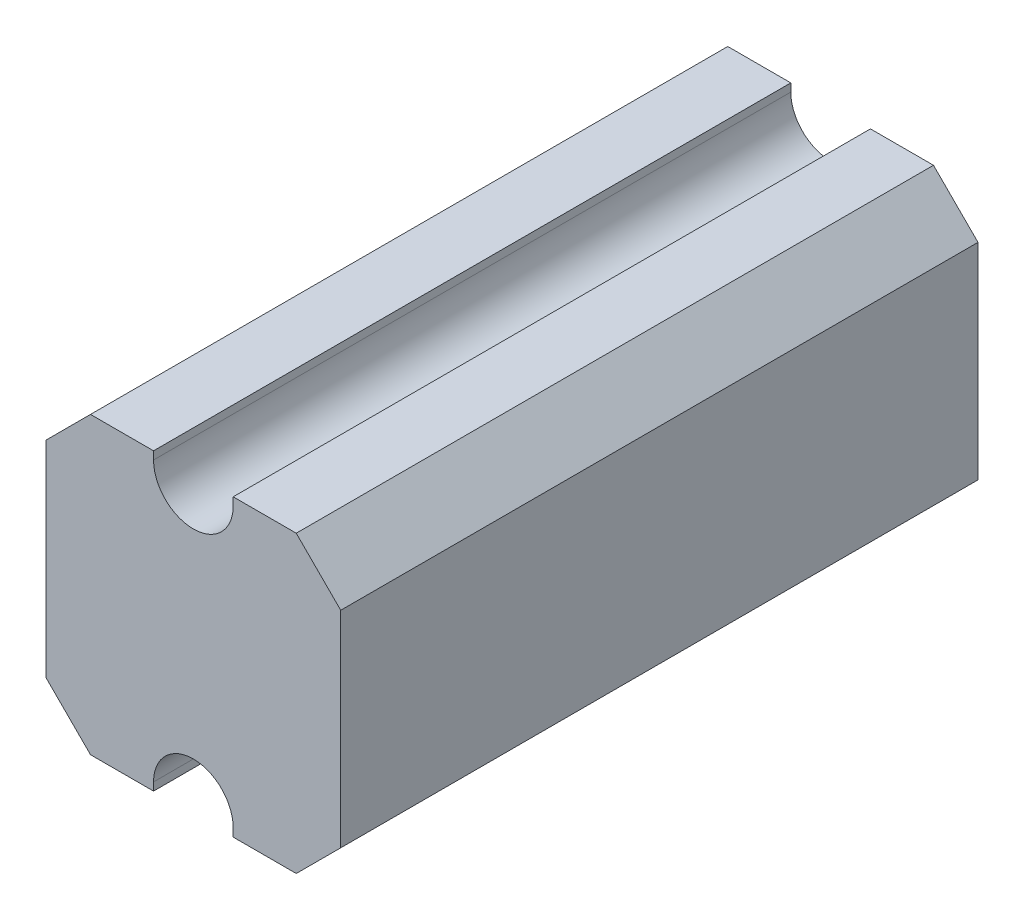
from build123d import *

# Parameters (mm, degrees)
BOSS_EXTRUDE1_DEPTH = 800


with BuildPart() as part:
    # Sketch1 → Boss-Extrude1 (new body)
    with BuildSketch(Plane.XY):
        with BuildLine():
            Line((-185, 129.142135624), (-185, -129.142135624))
            Line((-185, -129.142135624), (-129.142135624, -185))
            Line((-129.142135624, -185), (-50, -185))
            Line((-50, -185), (-50, -175))
            ThreePointArc((-50, -175), (0, -125), (50, -175))
            Line((50, -175), (50, -185))
            Line((50, -185), (129.142135624, -185))
            Line((129.142135624, -185), (185, -129.142135624))
            Line((185, -129.142135624), (185, 129.142135624))
            Line((185, 129.142135624), (129.142135624, 185))
            Line((129.142135624, 185), (50, 185))
            Line((50, 185), (50, 175))
            ThreePointArc((50, 175), (0, 125), (-50, 175))
            Line((-50, 175), (-50, 185))
            Line((-50, 185), (-129.142135624, 185))
            Line((-129.142135624, 185), (-185, 129.142135624))
        make_face()
    extrude(amount=-BOSS_EXTRUDE1_DEPTH)


solid = part.part
